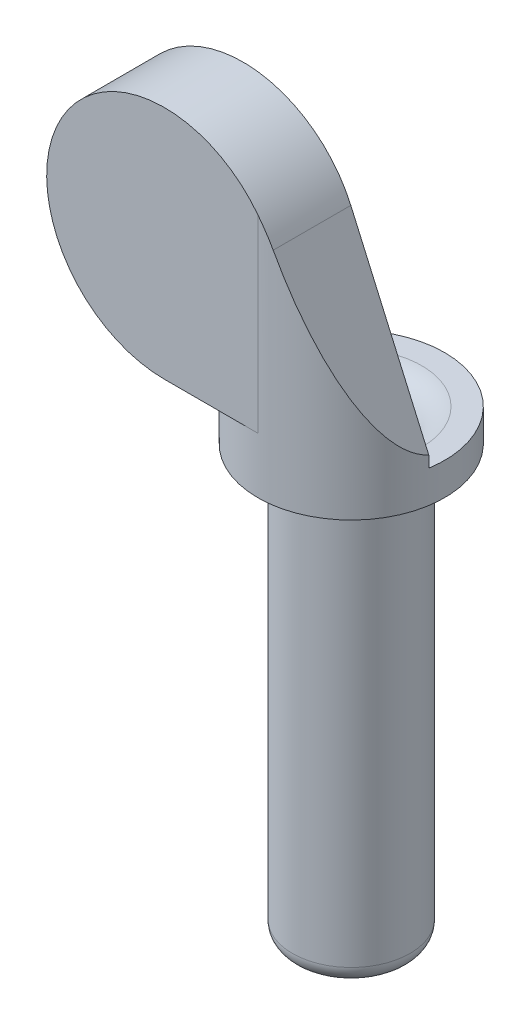
from build123d import *

# Parameters (mm, degrees)
SKETCH_1_R               = 2
EXTRUDE_1_DEPTH          = 16
EXTRUDE_2_DEPTH          = 3.175
SKETCH_4_R               = 1.65
CUT_EXTRUDE_6_DEPTH      = 2.5
SKETCH_5_W               = 10.65
SKETCH_5_H               = 0.5
CUT_EXTRUDE_8_DEPTH      = 9.5
FILLET_3_R               = 0.6
SKETCH_7_R               = 3.175
EXTRUDE_3_DEPTH          = 1.4
FILLET_5_R               = 0.3
CUT_EXTRUDE_9_DEPTH      = 1
CUT_EXTRUDE_9_DEPTH_BACK = 25.5
CUT_EXTRUDE_10_DEPTH     = 9.5
CUT_EXTRUDE_11_DEPTH     = 0.3
FILLET_6_R               = 1
CUT_EXTRUDE_12_DEPTH     = 0.5


with BuildPart() as part:
    # 草图1 → 凸台-拉伸1 (new body)
    with BuildSketch(Plane(origin=(0, 0, 0), x_dir=(1, 0, 0), z_dir=(0, 1, 0))):
        Circle(SKETCH_1_R)
    extrude(amount=EXTRUDE_1_DEPTH)

    # 草图2 → 凸台-拉伸2 (add)
    with BuildSketch(Plane.XY):
        with BuildLine():
            Line((3.175, 16), (0.486277818, 22.110914255))
            ThreePointArc((0.486277818, 22.110914255), (-6.524899776, 22.6859029), (-3.175, 16.5))
            Line((-3.175, 16.5), (-3.175, 16))
            Line((-3.175, 16), (3.175, 16))
        make_face()
    extrude(amount=EXTRUDE_2_DEPTH)

    # 草图4 → 切除-拉伸6 (cut)
    with BuildSketch(Plane(origin=(0, 0, 0), x_dir=(-1, 0, 0), z_dir=(0, 0, -1))):
        with Locations((3.175, 20.5)):
            Circle(SKETCH_4_R)
    extrude(amount=-CUT_EXTRUDE_6_DEPTH, mode=Mode.SUBTRACT)

    # 草图5 → 切除-拉伸8 (cut, through all)
    with BuildSketch(Plane(origin=(0, 16, 0), x_dir=(1, 0, 0), z_dir=(0, 1, 0))):
        with Locations((-2.15, -0.25)):
            Rectangle(SKETCH_5_W, SKETCH_5_H)
    extrude(amount=CUT_EXTRUDE_8_DEPTH, mode=Mode.SUBTRACT)

    # 圆角3
    fillet_3_edges = [part.edges().sort_by_distance(p)[0] for p in [
        (-2, 0, 0),
    ]]
    fillet(fillet_3_edges, radius=FILLET_3_R)

    # 草图7 → 凸台-拉伸3 (add)
    with BuildSketch(Plane(origin=(0, 16, 0), x_dir=(1, 0, 0), z_dir=(0, 1, 0))):
        Circle(SKETCH_7_R)
    extrude(amount=-EXTRUDE_3_DEPTH)

    # 圆角5
    fillet_5_edges = [part.edges().sort_by_distance(p)[0] for p in [
        (-1.525, 20.5, 0.5),
    ]]
    fillet(fillet_5_edges, radius=FILLET_5_R)

    # 草图10 → 切除-拉伸9 (cut, two sides)
    with BuildSketch(Plane.XZ) as cut_extrude_9_sk:
        with BuildLine():
            Line((-1.307669683, 0.5), (1.307669683, 0.5))
            ThreePointArc((1.307669683, 0.5), (0, -1.4), (-1.307669683, 0.5))
        make_face()
    extrude(amount=CUT_EXTRUDE_9_DEPTH, mode=Mode.SUBTRACT)
    extrude(cut_extrude_9_sk.sketch, amount=-CUT_EXTRUDE_9_DEPTH_BACK, mode=Mode.SUBTRACT)

    # 草图11 → 切除-拉伸10 (cut, through all)
    with BuildSketch(Plane.XZ.offset(-16)):
        with BuildLine():
            Line((3.175, 3.175), (0, 3.175))
            ThreePointArc((0, 3.175), (2.060718928, 2.415380405), (3.135382752, 0.5))
            Line((3.135382752, 0.5), (4.008589629, 0.5))
            Line((4.008589629, 0.5), (3.175, 3.175))
        make_face()
    extrude(amount=-CUT_EXTRUDE_10_DEPTH, mode=Mode.SUBTRACT)

    # 草图12 → 切除-拉伸11 (cut)
    with BuildSketch(Plane(origin=(0, 16, 0), x_dir=(1, 0, 0), z_dir=(0, 1, 0))):
        with BuildLine():
            Line((-3.135382752, -0.5), (3.135382752, -0.5))
            ThreePointArc((3.135382752, -0.5), (0, 3.175), (-3.135382752, -0.5))
        make_face()
    extrude(amount=-CUT_EXTRUDE_11_DEPTH, mode=Mode.SUBTRACT)

    # 圆角6
    fillet_6_edges = [part.edges().sort_by_distance(p)[0] for p in [
        (0, 15.7, -1.4),
    ]]
    fillet(fillet_6_edges, radius=FILLET_6_R)

    # 草图13 → 切除-拉伸12 (cut)
    with BuildSketch(Plane.XZ.offset(-16)):
        with BuildLine():
            Line((-3.135382752, 0.5), (-3.175, 0.5))
            Line((-3.175, 0.5), (-3.175, 3.175))
            Line((-3.175, 3.175), (0, 3.175))
            ThreePointArc((0, 3.175), (-2.060718928, 2.415380405), (-3.135382752, 0.5))
        make_face()
    extrude(amount=-CUT_EXTRUDE_12_DEPTH, mode=Mode.SUBTRACT)


solid = part.part
